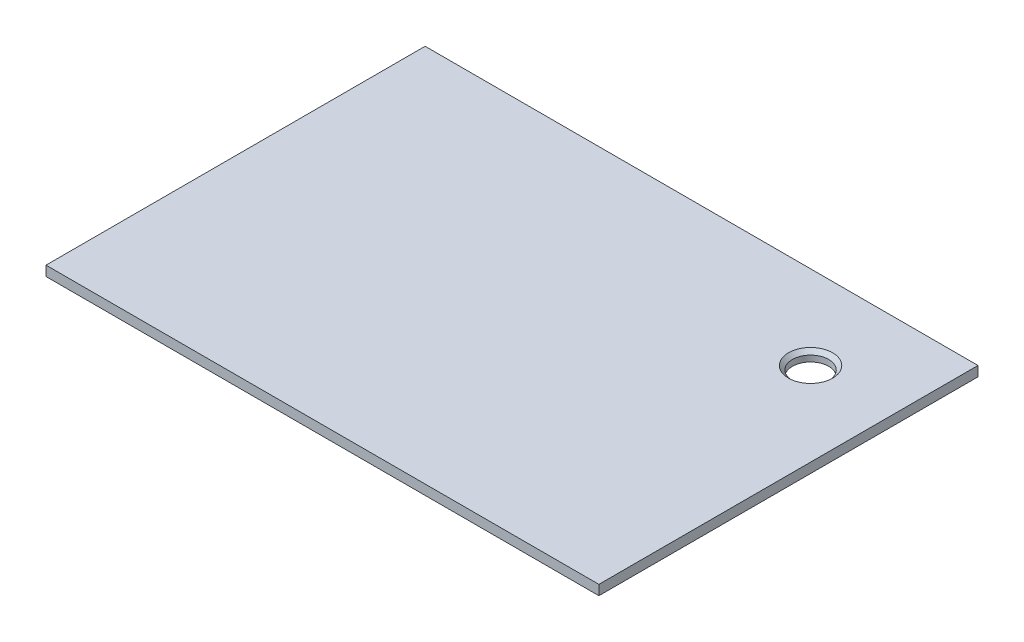
from build123d import *

# Parameters (mm, degrees)
SKETCH1_W                         = 175
SKETCH1_H                         = 120
BOSS_EXTRUDE1_DEPTH               = 3.125
F_1_2_20_TAPPED_HOLE1_D           = 11.50874
F_1_2_20_TAPPED_HOLE1_DEPTH       = 30
F_1_2_20_TAPPED_HOLE1_CSINK_D     = 13.97
F_1_2_20_TAPPED_HOLE1_CSINK_ANGLE = 90
F_1_2_20_TAPPED_HOLE1_TIP         = 3.45757432


with BuildPart() as part:
    # Sketch1 → Boss-Extrude1 (new body)
    with BuildSketch(Plane(origin=(0, 0, 0), x_dir=(1, 0, 0), z_dir=(0, 1, 0))):
        with Locations((87.5, 60)):
            Rectangle(SKETCH1_W, SKETCH1_H)
    extrude(amount=BOSS_EXTRUDE1_DEPTH)

    # 1/2-20 Tapped Hole1
    with Locations(Plane(origin=(0, 3.125, 0), x_dir=(1, 0, 0), z_dir=(0, 1, 0))):
        with Locations((148.5, 93.5)):
            CounterSinkHole(F_1_2_20_TAPPED_HOLE1_D / 2, F_1_2_20_TAPPED_HOLE1_CSINK_D / 2, depth=F_1_2_20_TAPPED_HOLE1_DEPTH, counter_sink_angle=F_1_2_20_TAPPED_HOLE1_CSINK_ANGLE)
            with Locations((0, 0, -(F_1_2_20_TAPPED_HOLE1_DEPTH + F_1_2_20_TAPPED_HOLE1_TIP / 2))):  # 118° drill point
                Cone(0, F_1_2_20_TAPPED_HOLE1_D / 2, F_1_2_20_TAPPED_HOLE1_TIP, mode=Mode.SUBTRACT)


solid = part.part
